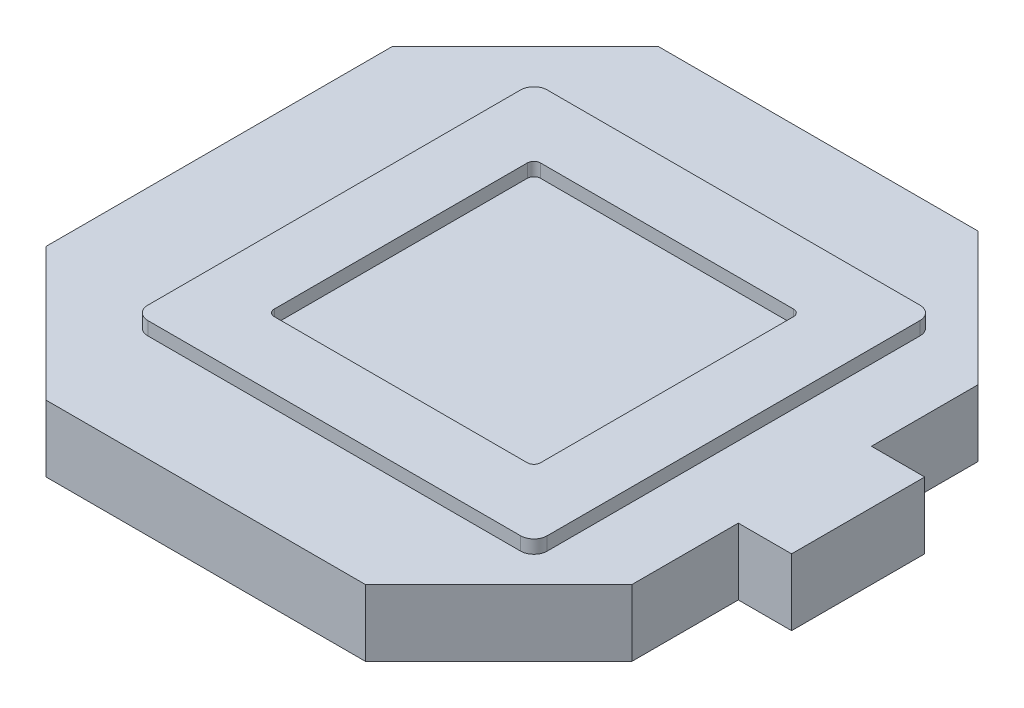
from build123d import *

# Parameters (mm, degrees)
BOSS_EXTRU_1_DEPTH      = 5
ESQUISSE2_W             = 30
ESQUISSE2_H             = 30
ESQUISSE2_W_2           = 20
ESQUISSE2_H_2           = 20
BOSS_EXTRU_2_DEPTH      = 1
ESQUISSE3_W             = 5
ESQUISSE3_H             = 5.2
ESQUISSE3_W_2           = 5.2
ESQUISSE3_H_2           = 5
ENL_V_MAT_EXTRU_1_DEPTH = 4.8
CONG_1_R                = 1
CONG_2_R                = 0.5


with BuildPart() as part:
    # Esquisse1 → Boss.-Extru.1 (new body)
    with BuildSketch(Plane(origin=(0, 0, 0), x_dir=(1, 0, 0), z_dir=(0, 1, 0))):
        Polygon((22, 13), (12.003020456, 23), (-12.003020456, 23), (-22, 13), (-22, -13), (-12.003020456, -23), (12.003020456, -23), (22, -13), (22, -5), (26, -5), (26, 5), (22, 5), align=None)
    extrude(amount=BOSS_EXTRU_1_DEPTH)

    # Esquisse2 → Boss.-Extru.2 (add)
    with BuildSketch(Plane(origin=(0, 5, 0), x_dir=(1, 0, 0), z_dir=(0, 1, 0))):
        with Locations((1.645517895, 0)):
            Rectangle(ESQUISSE2_W, ESQUISSE2_H)
        with Locations((1.645517895, 0)):
            Rectangle(ESQUISSE2_W_2, ESQUISSE2_H_2, mode=Mode.SUBTRACT)
    extrude(amount=BOSS_EXTRU_2_DEPTH)

    # Esquisse3 → Enlèv. mat.-Extru.1 (cut)
    with BuildSketch(Plane.XZ):
        with Locations((-13.5, 14.4)):
            Rectangle(ESQUISSE3_W, ESQUISSE3_H)
        with Locations((-13.4, -14.4)):
            Rectangle(ESQUISSE3_W_2, ESQUISSE3_H)
        with Locations((14.4, -14.4)):
            Rectangle(ESQUISSE3_W_2, ESQUISSE3_H)
        with Locations((13.4, 14.4)):
            Rectangle(ESQUISSE3_W_2, ESQUISSE3_H)
        Rectangle(ESQUISSE3_W, ESQUISSE3_H_2)
    extrude(amount=-ENL_V_MAT_EXTRU_1_DEPTH, mode=Mode.SUBTRACT)

    # Congé1
    cong_1_edges = [part.edges().sort_by_distance(p)[0] for p in [
        (16.645517895, 5.5, -15),
        (-13.354482105, 5.5, -15),
        (-13.354482105, 5.5, 15),
        (16.645517895, 5.5, 15),
    ]]
    fillet(cong_1_edges, radius=CONG_1_R)

    # Congé2
    cong_2_edges = [part.edges().sort_by_distance(p)[0] for p in [
        (-8.354482105, 5.5, -10),
        (-8.354482105, 5.5, 10),
        (11.645517895, 5.5, 10),
        (11.645517895, 5.5, -10),
    ]]
    fillet(cong_2_edges, radius=CONG_2_R)


solid = part.part
